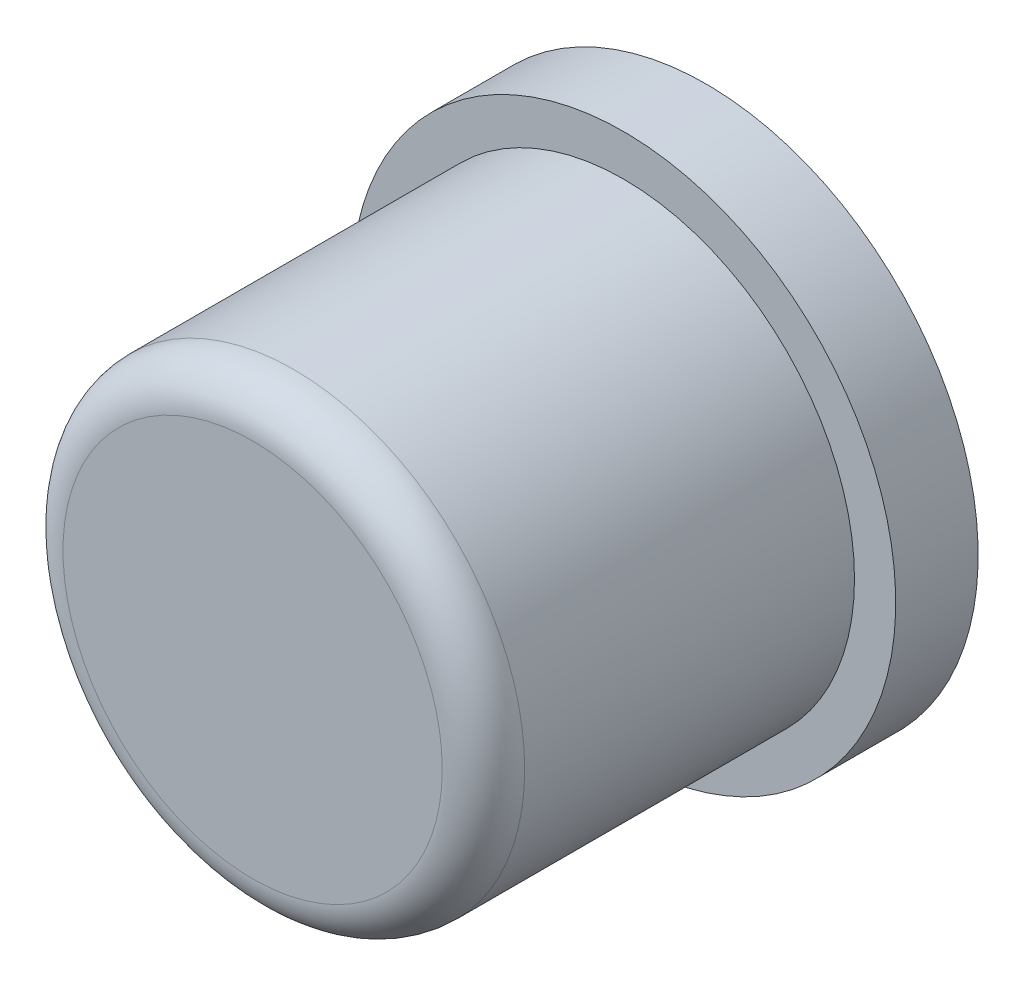
from build123d import *

# Parameters (mm, degrees)
SKETCH_1_R          = 2.8
EXTRUDE_1_DEPTH     = 5.5
SKETCH_2_R          = 3.3
EXTRUDE_2_DEPTH     = 1
SKETCH_3_R          = 2
CUT_EXTRUDE_1_DEPTH = 0.5
FILLET_1_R          = 0.5


with BuildPart() as part:
    # 草图1 → 凸台-拉伸1 (new body)
    with BuildSketch(Plane.XY):
        Circle(SKETCH_1_R)
    extrude(amount=EXTRUDE_1_DEPTH)

    # 草图2 → 凸台-拉伸2 (add)
    with BuildSketch(Plane(origin=(0, 0, 0), x_dir=(-1, 0, 0), z_dir=(0, 0, -1))):
        Circle(SKETCH_2_R)
    extrude(amount=-EXTRUDE_2_DEPTH)

    # 草图3 → 切除-拉伸1 (cut)
    with BuildSketch(Plane(origin=(0, 0, 0), x_dir=(-1, 0, 0), z_dir=(0, 0, -1))):
        Circle(SKETCH_3_R)
    extrude(amount=-CUT_EXTRUDE_1_DEPTH, mode=Mode.SUBTRACT)

    # 圆角1
    fillet_1_edges = [part.edges().sort_by_distance(p)[0] for p in [
        (-2.8, 0, 5.5),
    ]]
    fillet(fillet_1_edges, radius=FILLET_1_R)


solid = part.part
